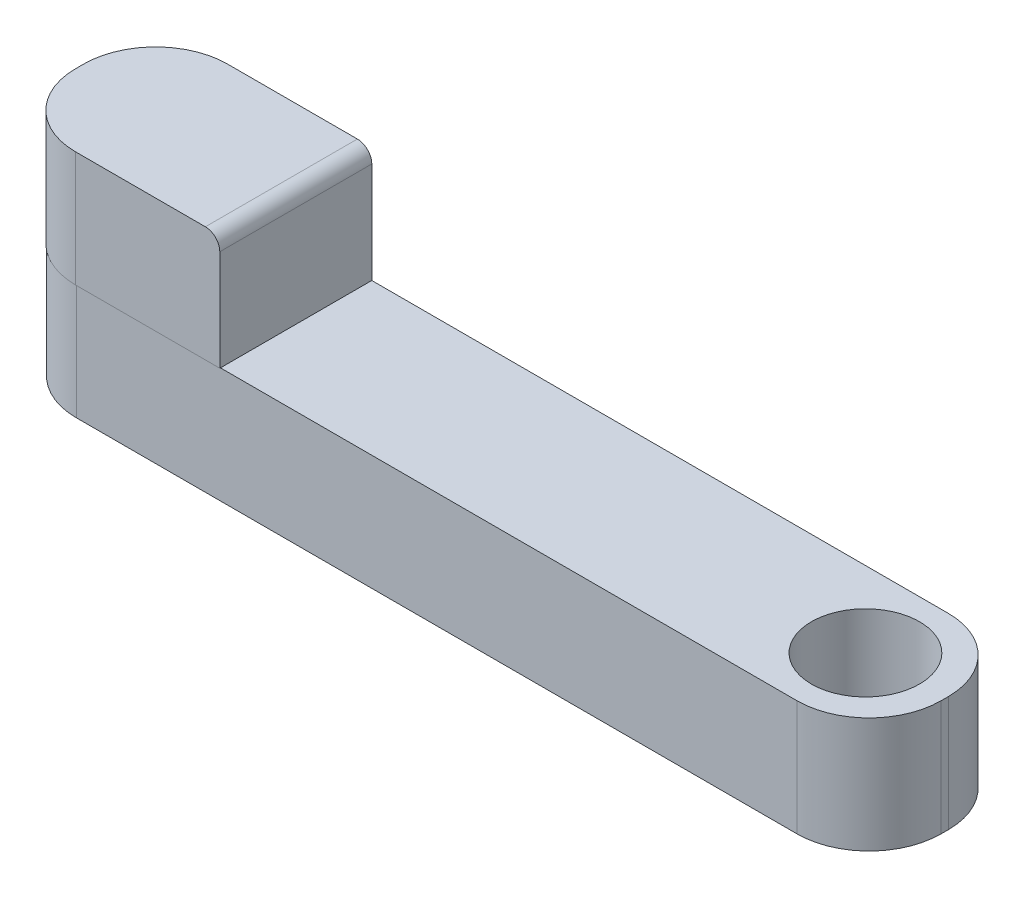
from build123d import *

# Parameters (mm, degrees)
SKETCH2_W           = 600
SKETCH2_H           = 105
SKETCH2_R           = 50
SKETCH2_R_2         = 37.5
BOSS_EXTRUDE2_DEPTH = 80
SKETCH3_W           = 150
SKETCH3_H           = 105.457586359
BOSS_EXTRUDE3_DEPTH = 80
SKETCH4_R           = 5
BOSS_EXTRUDE4_DEPTH = 120
FILLET1_R           = 10
FILLET3_R           = 50
FILLET4_R           = 50
FILLET5_R           = 50
FILLET6_R           = 50
FILLET7_R           = 50


with BuildPart() as part:
    # Sketch2 → Boss-Extrude2 (new body)
    with BuildSketch(Plane(origin=(0, 0, 0), x_dir=(1, 0, 0), z_dir=(0, 1, 0))):
        Rectangle(SKETCH2_W, SKETCH2_H)
        with Locations((-245, 0)):
            Circle(SKETCH2_R, mode=Mode.SUBTRACT)
        with Locations((245, 0)):
            Circle(SKETCH2_R_2, mode=Mode.SUBTRACT)
    extrude(amount=BOSS_EXTRUDE2_DEPTH)

    # Sketch3 → Boss-Extrude3 (add)
    with BuildSketch(Plane(origin=(0, 80, 0), x_dir=(1, 0, 0), z_dir=(0, 1, 0))):
        with Locations((-225, -0.22879318)):
            Rectangle(SKETCH3_W, SKETCH3_H)
    extrude(amount=BOSS_EXTRUDE3_DEPTH)

    # Sketch4 → Boss-Extrude4 (add)
    with BuildSketch(Plane.XZ.offset(-80)):
        with Locations((-245.135702484, 0)):
            Circle(SKETCH4_R)
    extrude(amount=BOSS_EXTRUDE4_DEPTH)

    # Fillet1
    fillet1_edges = [part.edges().sort_by_distance(p)[0] for p in [
        (-150, 160, 0.22879318),
    ]]
    fillet(fillet1_edges, radius=FILLET1_R)

    # Fillet3
    fillet3_edges = [part.edges().sort_by_distance(p)[0] for p in [
        (300, 40, 52.5),
    ]]
    fillet(fillet3_edges, radius=FILLET3_R)

    # Fillet4
    fillet4_edges = [part.edges().sort_by_distance(p)[0] for p in [
        (300, 40, -52.5),
    ]]
    fillet(fillet4_edges, radius=FILLET4_R)

    # Fillet5
    fillet5_edges = [part.edges().sort_by_distance(p)[0] for p in [
        (-300, 40, 52.5),
    ]]
    fillet(fillet5_edges, radius=FILLET5_R)

    # Fillet6
    fillet6_edges = [part.edges().sort_by_distance(p)[0] for p in [
        (-300, 120, 52.957586359),
    ]]
    fillet(fillet6_edges, radius=FILLET6_R)

    # Fillet7
    fillet7_edges = [part.edges().sort_by_distance(p)[0] for p in [
        (-300, 80, -52.5),
    ]]
    fillet(fillet7_edges, radius=FILLET7_R)


solid = part.part
